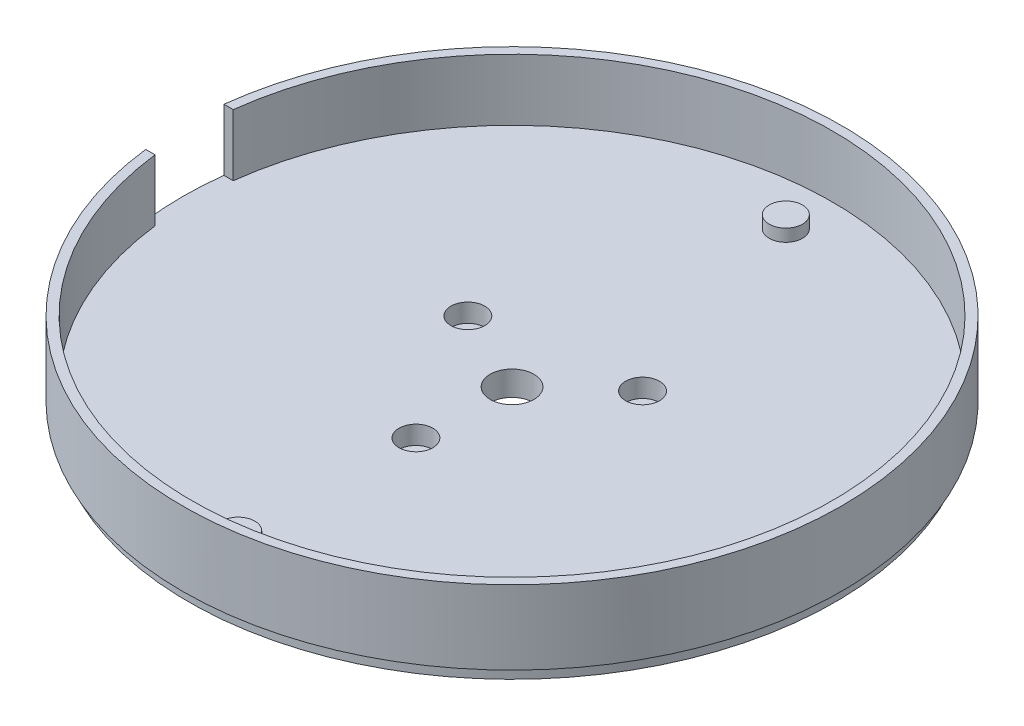
from build123d import *

# Parameters (mm, degrees)
SKETCH1_R           = 53.5
BOSS_EXTRUDE1_DEPTH = 2
SKETCH2_R           = 2.7
BOSS_EXTRUDE2_DEPTH = 2
SKETCH3_R           = 3.55
CUT_EXTRUDE1_DEPTH  = 2
SKETCH7_R           = 53.5
SKETCH7_R_2         = 52
BOSS_EXTRUDE3_DEPTH = 10
SKETCH8_W           = 56.651812746
SKETCH8_H           = 12.7
CUT_EXTRUDE4_DEPTH  = 10
SKETCH13_R          = 52.5
SKETCH13_R_2        = 3.55
BOSS_EXTRUDE4_DEPTH = 2
SKETCH12_R          = 2.75
CUT_EXTRUDE6_DEPTH  = 3
SKETCH16_R          = 1.5
CUT_EXTRUDE8_DEPTH  = 2


with BuildPart() as part:
    # Sketch1 → Boss-Extrude1 (new body)
    with BuildSketch(Plane(origin=(0, 0, 0), x_dir=(1, 0, 0), z_dir=(0, 1, 0))):
        Circle(SKETCH1_R)
    extrude(amount=BOSS_EXTRUDE1_DEPTH)

    # Sketch2 → Boss-Extrude2 (add)
    with BuildSketch(Plane(origin=(0, 2, 0), x_dir=(1, 0, 0), z_dir=(0, 1, 0))):
        with Locations((0, -44.45)):
            Circle(SKETCH2_R)
        with Locations((0, 44.45)):
            Circle(SKETCH2_R)
    extrude(amount=BOSS_EXTRUDE2_DEPTH)

    # Sketch3 → Cut-Extrude1 (cut)
    with BuildSketch(Plane(origin=(0, 2, 0), x_dir=(1, 0, 0), z_dir=(0, 1, 0))):
        Circle(SKETCH3_R)
    extrude(amount=-CUT_EXTRUDE1_DEPTH, mode=Mode.SUBTRACT)

    # Sketch7 → Boss-Extrude3 (add)
    with BuildSketch(Plane(origin=(0, 2, 0), x_dir=(1, 0, 0), z_dir=(0, 1, 0))):
        Circle(SKETCH7_R)
        Circle(SKETCH7_R_2, mode=Mode.SUBTRACT)
    extrude(amount=BOSS_EXTRUDE3_DEPTH)

    # Sketch8 → Cut-Extrude4 (cut)
    with BuildSketch(Plane(origin=(0, 2, 0), x_dir=(1, 0, 0), z_dir=(0, 1, 0))):
        with Locations((-28.325906373, 0)):
            Rectangle(SKETCH8_W, SKETCH8_H)
    extrude(amount=CUT_EXTRUDE4_DEPTH, mode=Mode.SUBTRACT)

    # Sketch13 → Boss-Extrude4 (add)
    with BuildSketch(Plane.XZ):
        Circle(SKETCH13_R)
        Circle(SKETCH13_R_2, mode=Mode.SUBTRACT)
    extrude(amount=BOSS_EXTRUDE4_DEPTH)

    # Sketch12 → Cut-Extrude6 (cut)
    with BuildSketch(Plane(origin=(0, 2, 0), x_dir=(1, 0, 0), z_dir=(0, 1, 0))):
        with Locations((11.16900504, 10.012658309)):
            Circle(SKETCH12_R)
        with Locations((-0.61610798, -14.987341691)):
            Circle(SKETCH12_R)
        with Locations((-13.568010506, 6.396021491)):
            Circle(SKETCH12_R)
    extrude(amount=-CUT_EXTRUDE6_DEPTH, mode=Mode.SUBTRACT)

    # Sketch16 → Cut-Extrude8 (cut, through all)
    with BuildSketch(Plane(origin=(0, -1, 0), x_dir=(1, 0, 0), z_dir=(0, 1, 0))):
        with Locations((11.16900504, 10.012658309)):
            Circle(SKETCH16_R)
        with Locations((-0.61610798, -14.987341691)):
            Circle(SKETCH16_R)
        with Locations((-13.568010506, 6.396021491)):
            Circle(SKETCH16_R)
    extrude(amount=-CUT_EXTRUDE8_DEPTH, mode=Mode.SUBTRACT)


solid = part.part
